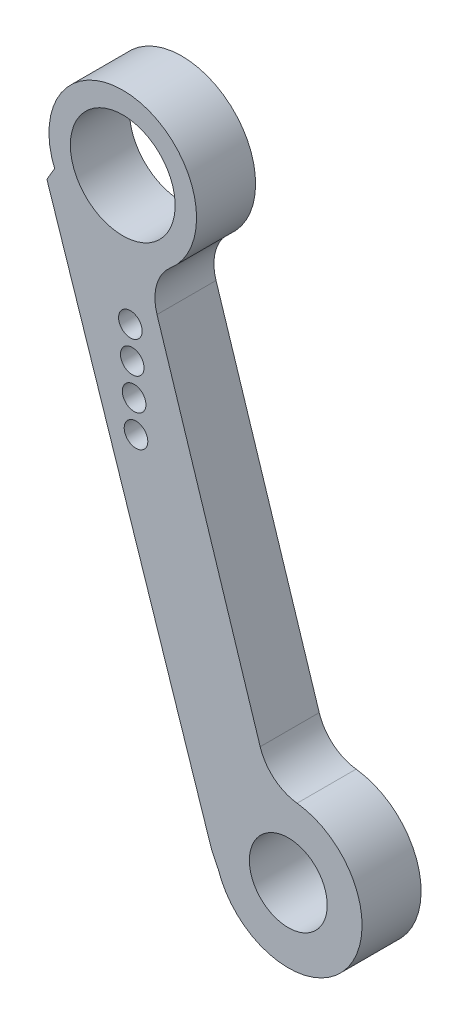
from build123d import *

# Parameters (mm, degrees)
SKETCH1_R           = 2.6375
SKETCH1_R_2         = 3.55
SKETCH1_R_3         = 0.8
BOSS_EXTRUDE1_DEPTH = 4


with BuildPart() as part:
    # Sketch1 → Boss-Extrude1 (new body)
    with BuildSketch(Plane.XY.offset(4)):
        with BuildLine():
            Line((4.361186649, 84.509770663), (3.838692378, 83.622901822))
            Line((3.838692378, 83.622901822), (15.011053362, 49.830662375))
            Line((15.011053362, 49.830662375), (15.45509163, 48.928599175))
            ThreePointArc((15.45509163, 48.928599175), (24.07294723, 47.365734356), (20.790472779, 55.485792426))
            ThreePointArc((20.790472779, 55.485792426), (19.237477826, 56.151424967), (18.290512878, 57.550752445))
            Line((18.290512878, 57.550752445), (11.299825408, 79.414245507))
            ThreePointArc((11.299825408, 79.414245507), (11.27305415, 81.153168904), (12.215576399, 82.614751297))
            ThreePointArc((12.215576399, 82.614751297), (10.152046635, 91.286695043), (4.361186649, 84.509770663))
        make_face()
        with Locations((20.194596002, 50.521426317)):
            Circle(SKETCH1_R, mode=Mode.SUBTRACT)
        with Locations((8.979351439, 86.426161535)):
            Circle(SKETCH1_R_2, mode=Mode.SUBTRACT)
        with Locations((9.4943608, 77.941777919)):
            Circle(SKETCH1_R_3, mode=Mode.SUBTRACT)
        with Locations((9.621598406, 75.845636084)):
            Circle(SKETCH1_R_3, mode=Mode.SUBTRACT)
        with Locations((9.748836013, 73.749494249)):
            Circle(SKETCH1_R_3, mode=Mode.SUBTRACT)
        with Locations((9.87607362, 71.653352414)):
            Circle(SKETCH1_R_3, mode=Mode.SUBTRACT)
    extrude(amount=-BOSS_EXTRUDE1_DEPTH)


solid = part.part
